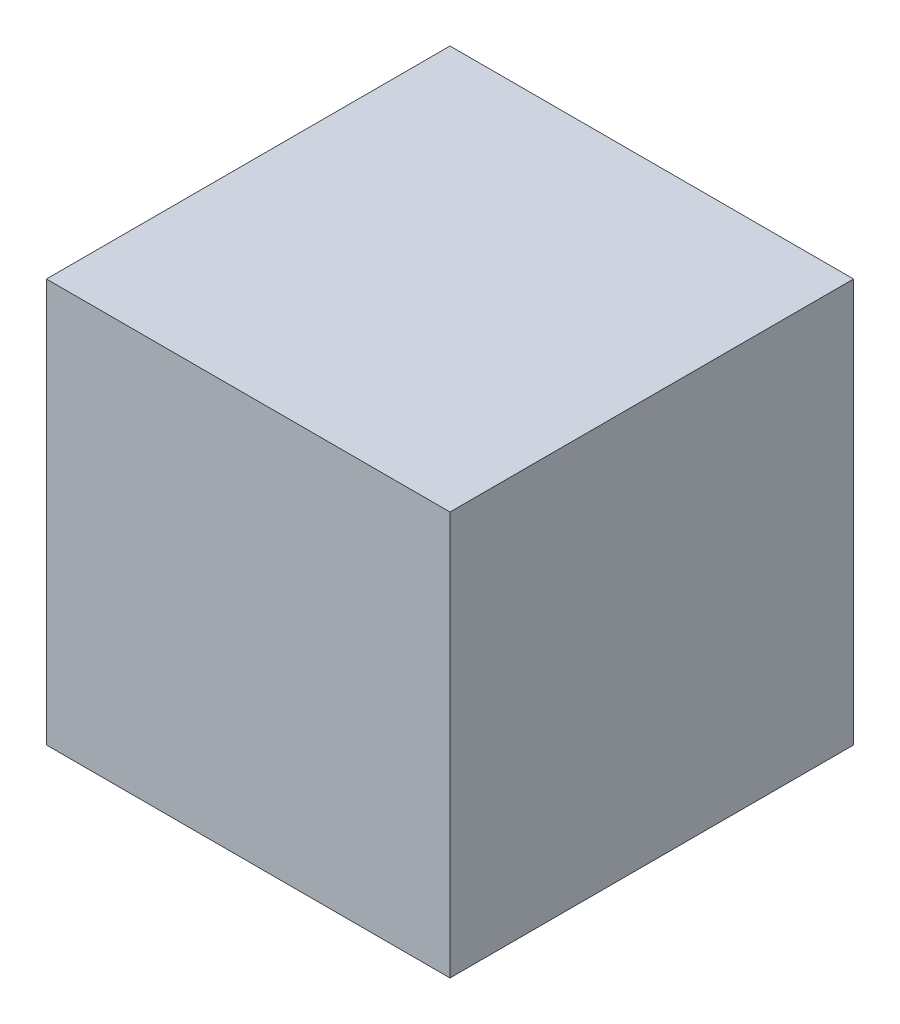
from build123d import *

# Parameters (mm, degrees)
SKETCH1_W           = 60
SKETCH1_H           = 60
BOSS_EXTRUDE1_DEPTH = 60


with BuildPart() as part:
    # Sketch1 → Boss-Extrude1 (new body)
    with BuildSketch(Plane.XY):
        Rectangle(SKETCH1_W, SKETCH1_H)
    extrude(amount=BOSS_EXTRUDE1_DEPTH)


solid = part.part
